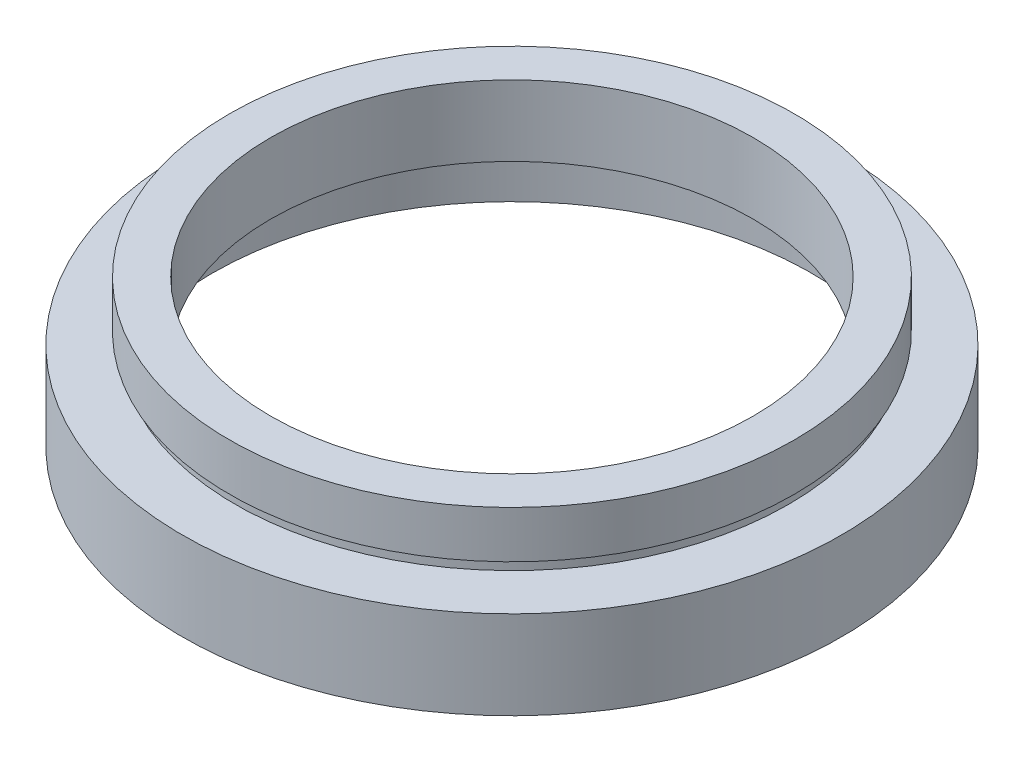
from build123d import *


with BuildPart() as part:
    # 草图1 → 旋转1 (revolve)
    with BuildSketch(Plane.XY, mode=Mode.PRIVATE) as revolve_1_sk:
        Polygon((25.5, 0), (25.5, 5.5), (26.1, 5.5), (26.1, 6.5), (20.5, 6.5), (20.5, 12.5), (24, 12.5), (24, 8.5), (23.5, 8.5), (23.5, 7.5), (28, 7.5), (28, 0), align=None)
    revolve(revolve_1_sk.sketch.rotate(Axis((0, 16.886018237, 0), (0, -1, 0)), 180), axis=Axis((0, 16.886018237, 0), (0, -1, 0)))  # turned: the seam where the file's is


solid = part.part
